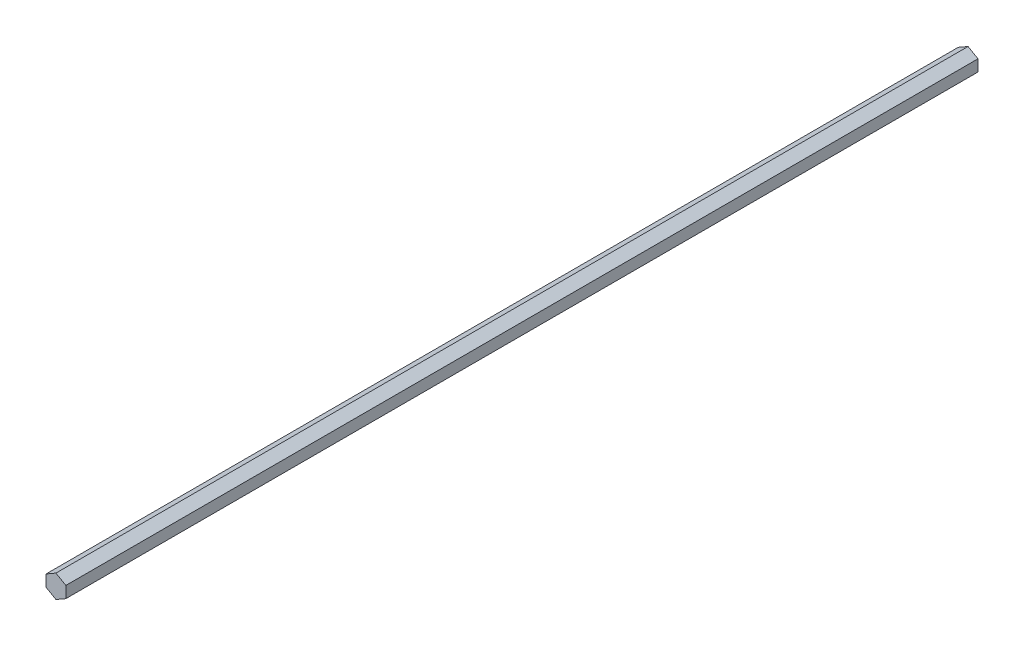
from build123d import *

# Parameters (mm, degrees)
BOSS_EXTRUDE1_DEPTH = 292.1


with BuildPart() as part:
    # Sketch1 → Boss-Extrude1 (new body, symmetric)
    with BuildSketch(Plane.XY):
        Polygon((0, 7.332348419), (-6.35, 3.666174209), (-6.35, -3.666174209), (0, -7.332348419), (6.35, -3.666174209), (6.35, 3.666174209), align=None)
    extrude(amount=BOSS_EXTRUDE1_DEPTH, both=True)


solid = part.part
